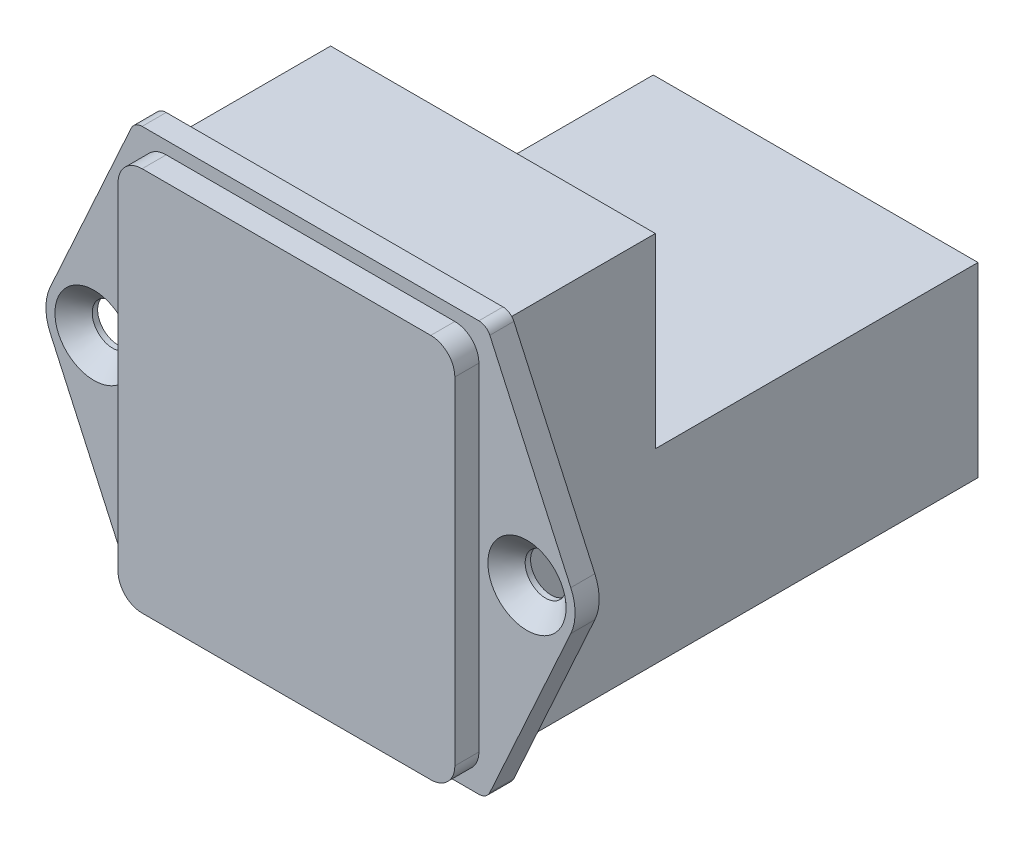
from build123d import *

# Parameters (mm, degrees)
SKETCH1_R                                       = 1.5
BOSS_EXTRUDE1_DEPTH                             = 2
BOSS_EXTRUDE2_DEPTH                             = 2
BOSS_EXTRUDE3_DEPTH                             = 13.5
CSK_FOR_M3_FLAT_HEAD_MACHINE_SCREW1_D           = 3.4
CSK_FOR_M3_FLAT_HEAD_MACHINE_SCREW1_CSINK_D     = 6.5
CSK_FOR_M3_FLAT_HEAD_MACHINE_SCREW1_CSINK_ANGLE = 90


with BuildPart() as part:
    # Sketch1 → Boss-Extrude1 (new body)
    with BuildSketch(Plane.XY):
        with BuildLine():
            Line((-21.64147317, 1.655195806), (-14.910368292, 16.463798951))
            ThreePointArc((-14.910368292, 16.463798951), (-14.541387592, 16.890773142), (-14, 17.05))
            Line((-14, 17.05), (14, 17.05))
            ThreePointArc((14, 17.05), (14.541387592, 16.890773142), (14.910368292, 16.463798951))
            Line((14.910368292, 16.463798951), (21.64147317, 1.655195806))
            ThreePointArc((21.64147317, 1.655195806), (22, 0), (21.64147317, -1.655195806))
            Line((21.64147317, -1.655195806), (14.910368292, -16.463798951))
            ThreePointArc((14.910368292, -16.463798951), (14.541387592, -16.890773142), (14, -17.05))
            Line((14, -17.05), (-14, -17.05))
            ThreePointArc((-14, -17.05), (-14.541387592, -16.890773142), (-14.910368292, -16.463798951))
            Line((-14.910368292, -16.463798951), (-21.64147317, -1.655195806))
            ThreePointArc((-21.64147317, -1.655195806), (-22, 0), (-21.64147317, 1.655195806))
        make_face()
        with Locations((-18, 0)):
            Circle(SKETCH1_R, mode=Mode.SUBTRACT)
        with Locations((18, 0)):
            Circle(SKETCH1_R, mode=Mode.SUBTRACT)
    extrude(amount=BOSS_EXTRUDE1_DEPTH)

    # Sketch2 → Boss-Extrude2 (add)
    with BuildSketch(Plane.XY.offset(2)):
        with BuildLine():
            Line((-12, 16), (12, 16))
            ThreePointArc((12, 16), (13.414213562, 15.414213562), (14, 14))
            Line((14, 14), (14, -14))
            ThreePointArc((14, -14), (13.414213562, -15.414213562), (12, -16))
            Line((12, -16), (-12, -16))
            ThreePointArc((-12, -16), (-13.414213562, -15.414213562), (-14, -14))
            Line((-14, -14), (-14, 14))
            ThreePointArc((-14, 14), (-13.414213562, 15.414213562), (-12, 16))
        make_face()
    extrude(amount=BOSS_EXTRUDE2_DEPTH)

    # Sketch3 → Boss-Extrude3 (add, symmetric)
    with BuildSketch(Plane(origin=(0, 0, 0), x_dir=(0, 0, -1), z_dir=(1, 0, 0))):
        Polygon((0, 15.5), (13.171636249, 15.5), (13.171636249, 0), (40, 0), (40, -15.5), (0, -15.5), align=None)
    extrude(amount=BOSS_EXTRUDE3_DEPTH, both=True)

    # CSK for M3 Flat Head Machine Screw1 (through all)
    with Locations(Plane.XY.offset(2)):
        with Locations((-18, 0), (18, 0)):
            CounterSinkHole(CSK_FOR_M3_FLAT_HEAD_MACHINE_SCREW1_D / 2, CSK_FOR_M3_FLAT_HEAD_MACHINE_SCREW1_CSINK_D / 2, counter_sink_angle=CSK_FOR_M3_FLAT_HEAD_MACHINE_SCREW1_CSINK_ANGLE)


solid = part.part
